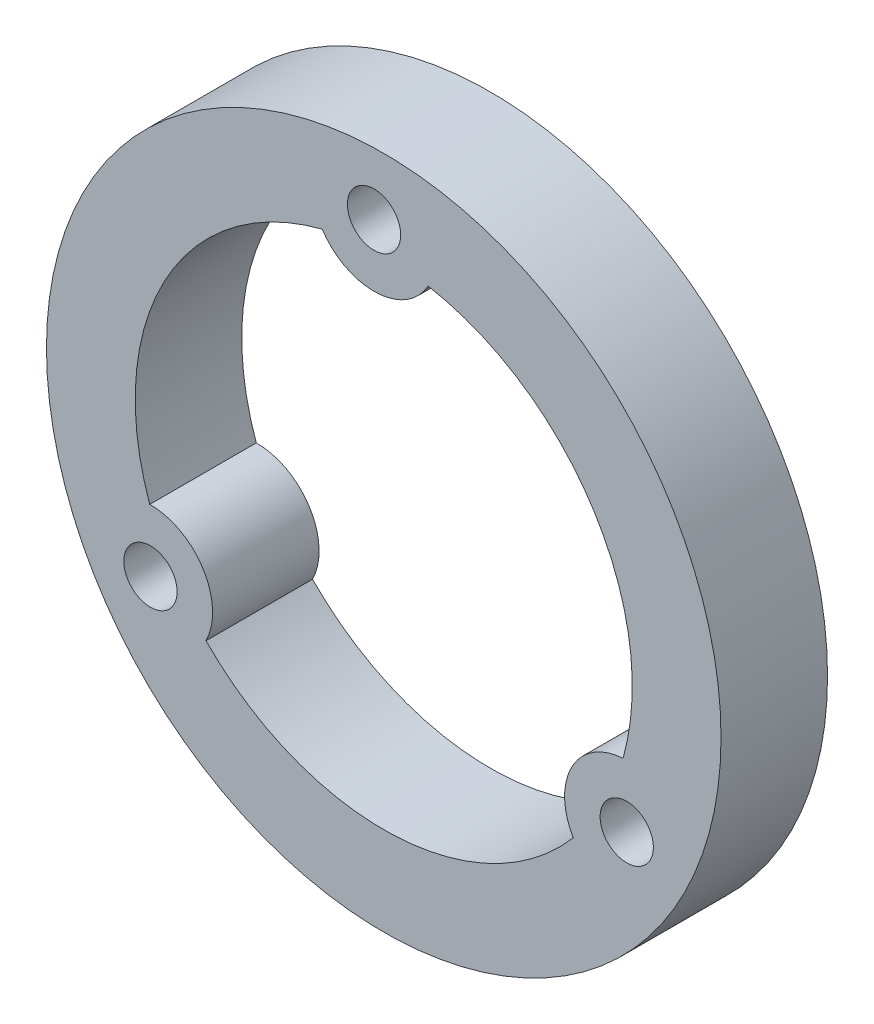
from build123d import *

# Parameters (mm, degrees)
ESQUISSE1_R        = 19
ESQUISSE1_R_2      = 1.5
BOSS_EXTRU_2_DEPTH = 6


with BuildPart() as part:
    # Esquisse1 → Boss.-Extru.2 (new body)
    with BuildSketch(Plane.XY):
        Circle(ESQUISSE1_R)
        with Locations((-0.546712729, 15.490355231)):
            Circle(ESQUISSE1_R_2, mode=Mode.SUBTRACT)
        with Locations((-13.14168478, -8.218644727)):
            Circle(ESQUISSE1_R_2, mode=Mode.SUBTRACT)
        with Locations((13.688397508, -7.271710504)):
            Circle(ESQUISSE1_R_2, mode=Mode.SUBTRACT)
        with BuildLine():
            ThreePointArc((-3.468577117, 13.56351624), (-0.423261467, 11.992533082), (2.503723019, 13.774301109))
            ThreePointArc((2.503723019, 13.774301109), (11.869908833, 7.423292012), (13.480638187, -3.777882222))
            ThreePointArc((13.480638187, -3.777882222), (10.597469039, -5.629711358), (10.677033171, -9.055438293))
            ThreePointArc((10.677033171, -9.055438293), (0.493805045, -13.991288596), (-10.01206107, -9.785634018))
            ThreePointArc((-10.01206107, -9.785634018), (-10.174207571, -6.362821724), (-13.180756189, -4.718862816))
            ThreePointArc((-13.180756189, -4.718862816), (-12.363713879, 6.567996584), (-3.468577117, 13.56351624))
        make_face(mode=Mode.SUBTRACT)
    extrude(amount=BOSS_EXTRU_2_DEPTH)


solid = part.part
